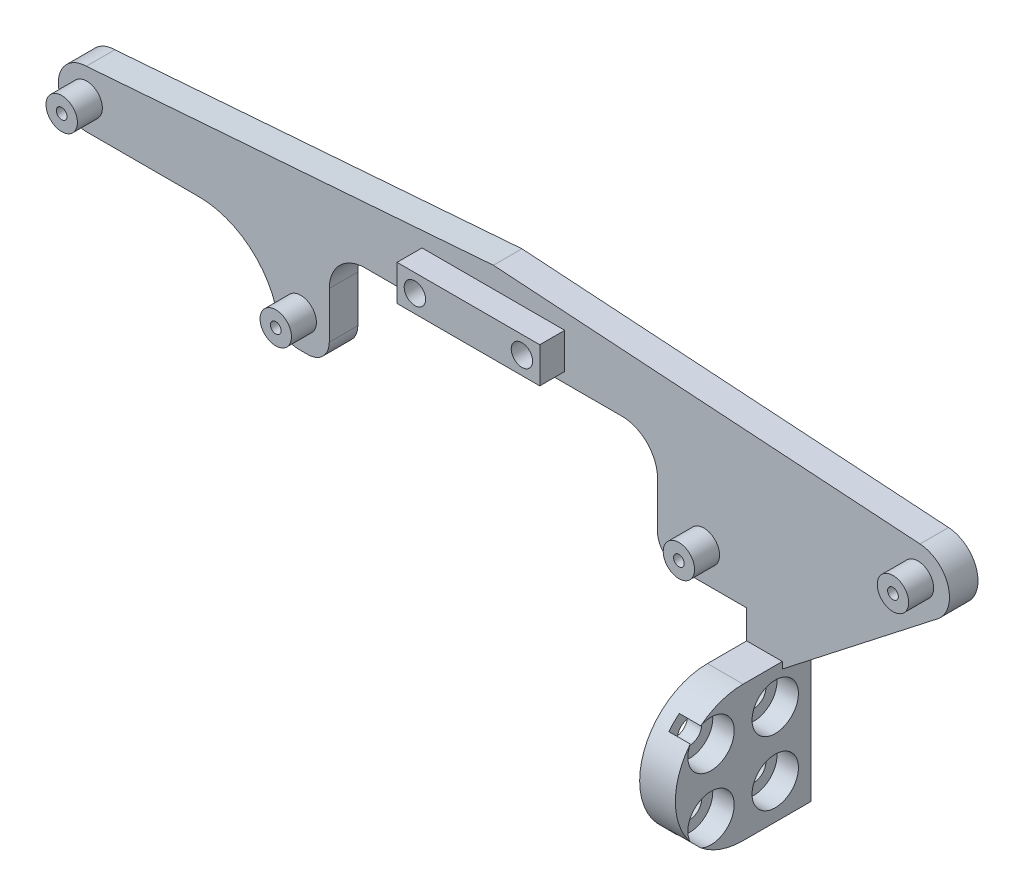
from build123d import *

# Parameters (mm, degrees)
BOSS_EXTRUDE1_DEPTH            = 4
SKETCH2_R                      = 2.2
BOSS_EXTRUDE2_DEPTH            = 3.5
SKETCH3_R                      = 0.75
CUT_EXTRUDE1_DEPTH             = 8.5
SKETCH4_R                      = 2.2
BOSS_EXTRUDE3_DEPTH            = 3.5
SKETCH5_R                      = 0.75
CUT_EXTRUDE2_DEPTH             = 8.5
SKETCH6_R                      = 2.2
BOSS_EXTRUDE4_DEPTH            = 3.5
SKETCH7_R                      = 0.75
CUT_EXTRUDE3_DEPTH             = 8.5
SKETCH8_R                      = 2.2
BOSS_EXTRUDE5_DEPTH            = 3.5
SKETCH9_R                      = 0.75
CUT_EXTRUDE4_DEPTH             = 8.5
SKETCH10_W                     = 20
SKETCH10_H                     = 5
BOSS_EXTRUDE6_DEPTH            = 3.5
SKETCH11_R                     = 1.5
CUT_EXTRUDE5_DEPTH             = 8.5
BOSS_EXTRUDE8_DEPTH            = 5
CBORE_FOR_M3_SHCS1_D           = 3.4
CBORE_FOR_M3_SHCS1_CBORE_D     = 6.5
CBORE_FOR_M3_SHCS1_CBORE_DEPTH = 3
FILLET1_R                      = 5
FILLET2_R                      = 3


with BuildPart() as part:
    # Sketch1 → Boss-Extrude1 (new body)
    with BuildSketch(Plane.XY):
        with BuildLine():
            Line((0, 0), (59.790168207, -3.934842784))
            ThreePointArc((59.790168207, -3.934842784), (63.68729409, -6.932891166), (62.399590235, -11.678173352))
            Line((62.399590235, -11.678173352), (40.5, -28.758482209))
            Line((40.5, -28.758482209), (40.5, -46.843965811))
            Line((40.5, -46.843965811), (35.5, -46.843965811))
            Line((35.5, -46.843965811), (35.5, -23.843965811))
            Line((35.5, -23.843965811), (23, -23.843965811))
            Line((23, -23.843965811), (23, -9.315581275))
            Line((23, -9.315581275), (-23, -9.315581275))
            Line((-23, -9.315581275), (-23, -23.843965815))
            Line((-23, -23.843965815), (-30, -23.843965815))
            Line((-30, -23.843965815), (-30, -23.624609813))
            ThreePointArc((-30, -23.624609813), (-33.311090065, -15.630931272), (-41.304768605, -12.319841207))
            Line((-41.304768605, -12.319841207), (-57, -12.319841207))
            ThreePointArc((-57, -12.319841207), (-60.975796988, -8.36893525), (-57.049937893, -4.368404043))
            Line((-57.049937893, -4.368404043), (0, 0))
        make_face()
    extrude(amount=BOSS_EXTRUDE1_DEPTH)

    # Sketch2 → Boss-Extrude2 (add)
    with BuildSketch(Plane.XY.offset(4)):
        with Locations((59.5, -8.343965811)):
            Circle(SKETCH2_R)
    extrude(amount=BOSS_EXTRUDE2_DEPTH)

    # Sketch3 → Cut-Extrude1 (cut, through all)
    with BuildSketch(Plane.XY.offset(7.5)):
        with Locations((59.5, -8.343965811)):
            Circle(SKETCH3_R)
    extrude(amount=-CUT_EXTRUDE1_DEPTH, mode=Mode.SUBTRACT)

    # Sketch4 → Boss-Extrude3 (add)
    with BuildSketch(Plane.XY.offset(4)):
        with Locations((29.5, -19.343965811)):
            Circle(SKETCH4_R)
    extrude(amount=BOSS_EXTRUDE3_DEPTH)

    # Sketch5 → Cut-Extrude2 (cut, through all)
    with BuildSketch(Plane.XY.offset(7.5)):
        with Locations((29.5, -19.343965811)):
            Circle(SKETCH5_R)
    extrude(amount=-CUT_EXTRUDE2_DEPTH, mode=Mode.SUBTRACT)

    # Sketch6 → Boss-Extrude4 (add)
    with BuildSketch(Plane.XY.offset(4)):
        with Locations((-57, -8.343965811)):
            Circle(SKETCH6_R)
    extrude(amount=BOSS_EXTRUDE4_DEPTH)

    # Sketch7 → Cut-Extrude3 (cut, through all)
    with BuildSketch(Plane.XY.offset(7.5)):
        with Locations((-57, -8.343965811)):
            Circle(SKETCH7_R)
    extrude(amount=-CUT_EXTRUDE3_DEPTH, mode=Mode.SUBTRACT)

    # Sketch8 → Boss-Extrude5 (add)
    with BuildSketch(Plane.XY.offset(4)):
        with Locations((-27, -19.343965811)):
            Circle(SKETCH8_R)
    extrude(amount=BOSS_EXTRUDE5_DEPTH)

    # Sketch9 → Cut-Extrude4 (cut, through all)
    with BuildSketch(Plane.XY.offset(7.5)):
        with Locations((-27, -19.343965811)):
            Circle(SKETCH9_R)
    extrude(amount=-CUT_EXTRUDE4_DEPTH, mode=Mode.SUBTRACT)

    # Sketch10 → Boss-Extrude6 (add)
    with BuildSketch(Plane.XY.offset(4)):
        with Locations((0, -5.399210768)):
            Rectangle(SKETCH10_W, SKETCH10_H)
    extrude(amount=BOSS_EXTRUDE6_DEPTH)

    # Sketch11 → Cut-Extrude5 (cut, through all)
    with BuildSketch(Plane.XY.offset(7.5)):
        with Locations((-7.5, -5.399210768)):
            Circle(SKETCH11_R)
        with Locations((7.5, -5.399210768)):
            Circle(SKETCH11_R)
    extrude(amount=-CUT_EXTRUDE5_DEPTH, mode=Mode.SUBTRACT)

    # Sketch12 → Boss-Extrude8 (add)
    with BuildSketch(Plane(origin=(40.5, 0, 0), x_dir=(0, 0, -1), z_dir=(1, 0, 0))):
        with BuildLine():
            ThreePointArc((-4, -29.597999119), (-6.613538808, -28.293090617), (-9.5, -27.843965811))
            Line((-9.5, -27.843965811), (-9.5, -46.843965811))
            ThreePointArc((-9.5, -46.843965811), (-6.613538808, -46.394841006), (-4, -45.089932504))
            Line((-4, -45.089932504), (-4, -29.597999119))
        make_face()
        with BuildLine():
            Line((-4, -27.843965811), (-9.5, -27.843965811))
            ThreePointArc((-9.5, -27.843965811), (-6.613538808, -28.293090617), (-4, -29.597999119))
            Line((-4, -29.597999119), (-4, -27.843965811))
        make_face()
        with BuildLine():
            Line((-9.5, -46.843965811), (-9.5, -27.843965811))
            ThreePointArc((-9.5, -27.843965811), (-19, -37.343965811), (-9.5, -46.843965811))
        make_face()
        with BuildLine():
            ThreePointArc((-4, -45.089932504), (-6.613538808, -46.394841006), (-9.5, -46.843965811))
            Line((-9.5, -46.843965811), (-4, -46.843965811))
            Line((-4, -46.843965811), (-4, -45.089932504))
        make_face()
        with BuildLine():
            ThreePointArc((0, -37.343965811), (-1.059028492, -32.985066868), (-4, -29.597999119))
            Line((-4, -29.597999119), (-4, -45.089932504))
            ThreePointArc((-4, -45.089932504), (-1.059028492, -41.702864755), (0, -37.343965811))
        make_face()
    extrude(amount=-BOSS_EXTRUDE8_DEPTH)

    # CBORE for M3 SHCS1 (through all)
    with Locations(Plane(origin=(40.5, -32.843965811, 14), x_dir=(0, 0, 1), z_dir=(1, 0, 0))):
        with Locations((0, 0), (-9, 0), (0, 9), (-9, 9)):
            CounterBoreHole(CBORE_FOR_M3_SHCS1_D / 2, CBORE_FOR_M3_SHCS1_CBORE_D / 2, CBORE_FOR_M3_SHCS1_CBORE_DEPTH)

    # Fillet1
    fillet1_edges = [part.edges().sort_by_distance(p)[0] for p in [
        (23, -9.315581275, 2),
        (-23, -9.315581275, 2),
    ]]
    fillet(fillet1_edges, radius=FILLET1_R)

    # Fillet2
    fillet2_edges = [part.edges().sort_by_distance(p)[0] for p in [
        (-30, -23.843965815, 2),
        (23, -23.843965811, 2),
        (-23, -23.843965815, 2),
    ]]
    fillet(fillet2_edges, radius=FILLET2_R)


solid = part.part
